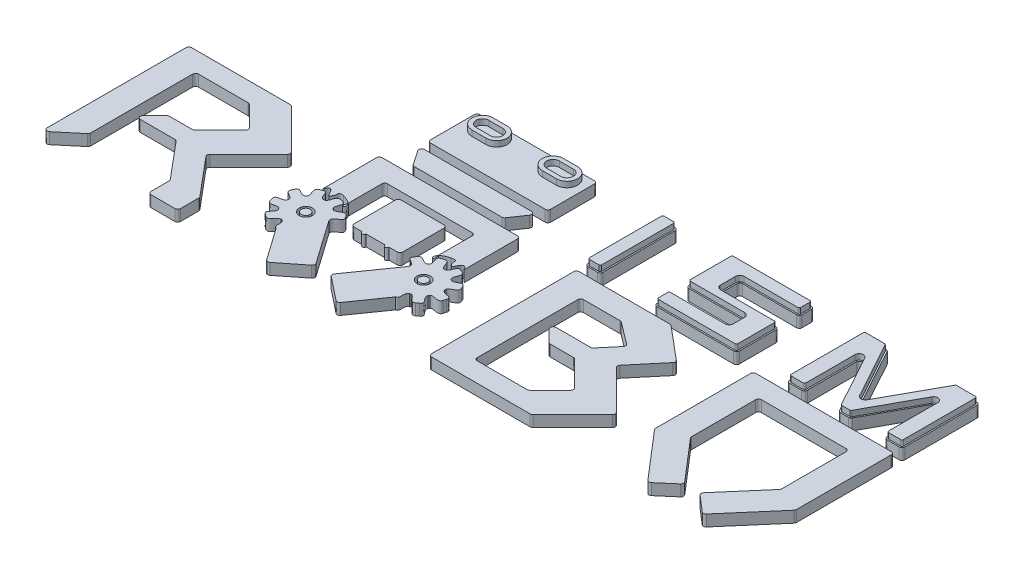
from build123d import *

# Parameters (mm, degrees)
BOSS_EXTRUDE1_DEPTH    = 40
BOSS_EXTRUDE1_2_DEPTH  = 40
BOSS_EXTRUDE1_3_DEPTH  = 40
SKETCH1_R              = 23.479951484
BOSS_EXTRUDE1_4_DEPTH  = 40
BOSS_EXTRUDE1_5_DEPTH  = 40
BOSS_EXTRUDE1_6_DEPTH  = 40
BOSS_EXTRUDE1_7_DEPTH  = 40
BOSS_EXTRUDE1_8_DEPTH  = 40
BOSS_EXTRUDE1_9_DEPTH  = 40
BOSS_EXTRUDE1_10_DEPTH = 40
BOSS_EXTRUDE1_11_DEPTH = 40
BOSS_EXTRUDE1_12_DEPTH = 40
SKETCH1_R_2            = 15.700674002
BOSS_EXTRUDE1_13_DEPTH = 40
BOSS_EXTRUDE1_14_DEPTH = 40
BOSS_EXTRUDE3_DEPTH    = 60


with BuildPart() as part:
    # Sketch1 → Boss-Extrude1 (new body)
    with BuildSketch(Plane(origin=(0, 0, 0), x_dir=(1, 0, 0), z_dir=(0, 1, 0))):
        with BuildLine():
            ThreePointArc((-83.841154636, -502.562147273), (-78.067337254, -511.625225143), (-67.41327854, -510.222591704))
            Line((-67.41327854, -510.222591704), (5.672852656, -448.896045973))
            ThreePointArc((5.672852656, -448.896045973), (8.30805443, -445.46178416), (9.244976559, -441.235601542))
            Line((9.244976559, -441.235601542), (9.244976559, -79.067718573))
            ThreePointArc((9.244976559, -79.067718573), (12.173908747, -71.996650761), (19.244976559, -69.067718573))
            Line((19.244976559, -69.067718573), (195.884712535, -69.067718573))
            ThreePointArc((195.884712535, -69.067718573), (199.711546859, -69.828923248), (202.955780347, -71.996650761))
            Line((202.955780347, -71.996650761), (275.159008185, -144.199878599))
            ThreePointArc((275.159008185, -144.199878599), (278.087940373, -151.270946411), (275.159008185, -158.342014222))
            Line((275.159008185, -158.342014222), (186.164058819, -247.336963589))
            ThreePointArc((186.164058819, -247.336963589), (182.91982533, -249.504691102), (179.092991007, -250.265895777))
            Line((179.092991007, -250.265895777), (97.377262254, -250.265895777))
            ThreePointArc((97.377262254, -250.265895777), (93.55042793, -251.027100452), (90.306194442, -253.194827965))
            Line((90.306194442, -253.194827965), (48.956172038, -294.544850369))
            ThreePointArc((48.956172038, -294.544850369), (46.788444525, -305.442752505), (56.02723985, -311.615918181))
            Line((56.02723985, -311.615918181), (178.572050049, -311.615918181))
            ThreePointArc((178.572050049, -311.615918181), (182.798232666, -312.552840311), (186.23249448, -315.188042084))
            Line((186.23249448, -315.188042084), (293.572185403, -443.11050437))
            ThreePointArc((293.572185403, -443.11050437), (295.30866718, -446.118179033), (295.911740972, -449.538380466))
            Line((295.911740972, -449.538380466), (295.911740972, -514.007216478))
            ThreePointArc((295.911740972, -514.007216478), (298.84067316, -521.07828429), (305.911740972, -524.007216478))
            Line((305.911740972, -524.007216478), (390.968639604, -524.007216478))
            ThreePointArc((390.968639604, -524.007216478), (398.039707415, -521.07828429), (400.968639604, -514.007216478))
            Line((400.968639604, -514.007216478), (400.968639604, -449.538380466))
            ThreePointArc((400.968639604, -449.538380466), (400.365565811, -446.118179033), (398.629084035, -443.11050437))
            Line((398.629084035, -443.11050437), (285.982871093, -308.863975404))
            ThreePointArc((285.982871093, -308.863975404), (283.652833308, -301.999905433), (286.572247712, -295.365031495))
            Line((286.572247712, -295.365031495), (423.897571792, -158.039707415))
            ThreePointArc((423.897571792, -158.039707415), (426.82650398, -150.968639604), (423.897571792, -143.897571792))
            Line((423.897571792, -143.897571792), (282.928932188, -2.928932188))
            ThreePointArc((282.928932188, -2.928932188), (279.6846987, -0.761204675), (275.857864376, 0))
            Line((275.857864376, 0), (-73.841154636, 0))
            ThreePointArc((-73.841154636, 0), (-80.912222448, -2.928932188), (-83.841154636, -10))
            Line((-83.841154636, -10), (-83.841154636, -502.562147273))
        make_face()
    extrude(amount=BOSS_EXTRUDE1_DEPTH)


with BuildPart() as body_2:
    # Sketch1 → Boss-Extrude1 2 (new body)
    with BuildSketch(Plane(origin=(0, 0, 0), x_dir=(1, 0, 0), z_dir=(0, 1, 0))):
        with BuildLine():
            ThreePointArc((652.48855838, 100.131688406), (643.639472479, 94.789335744), (644.245374102, 84.470424151))
            Line((644.245374102, 84.470424151), (678.948658716, 33.940090771))
            ThreePointArc((678.948658716, 33.940090771), (682.534195656, 30.752269125), (687.191842994, 29.601355025))
            Line((687.191842994, 29.601355025), (997.617211156, 29.601355025))
            ThreePointArc((997.617211156, 29.601355025), (1002.274858494, 30.752269125), (1005.860395434, 33.940090771))
            Line((1005.860395434, 33.940090771), (1040.563680048, 84.470424151))
            ThreePointArc((1040.563680048, 84.470424151), (1041.169581671, 94.789335744), (1032.32049577, 100.131688406))
            Line((1032.32049577, 100.131688406), (652.48855838, 100.131688406))
        make_face()
    extrude(amount=BOSS_EXTRUDE1_2_DEPTH)


with BuildPart() as body_3:
    # Sketch1 → Boss-Extrude1 3 (new body)
    with BuildSketch(Plane(origin=(0, 0, 0), x_dir=(1, 0, 0), z_dir=(0, 1, 0))):
        with BuildLine():
            ThreePointArc((682.229399989, -80.93218663), (685.158332177, -73.861118818), (692.229399989, -70.93218663))
            Line((692.229399989, -70.93218663), (992.552480119, -70.93218663))
            ThreePointArc((992.552480119, -70.93218663), (999.633135852, -73.870719757), (1002.552443298, -80.959323751))
            Line((1002.552443298, -80.959323751), (1002.229399989, -200))
            add(Edge.make_bspline(
                [(1002.321143043, -199.936731223), (1002.916384647, -199.672681374), (1002.869221848, -206.618046373), (1005.300085939, -210.274432477), (1005.476733332, -215.952627703), (1001.990741796, -221.163267153), (995.909387929, -215.485813233), (998.028575655, -207.97313609), (1000.304866893, -203.736781043), (1002.000226532, -200.210083042), (1002.229399989, -200)],
                knots=[0, 0, 0, 0, 0.110724906, 0.248079989, 0.387954105, 0.472257206, 0.599066129, 0.783281331, 0.956008664, 0.994591562, 0.994591562, 0.994591562, 0.994591562], degree=3))
            add(Edge.make_bspline(
                [(1032.936175395, -185.803412229), (1021.570991454, -188.809211315), (1011.635940703, -193.520317646), (1002.321143043, -199.936731223)],
                knots=[0, 0, 0, 0, 0.996726796, 0.996726796, 0.996726796, 0.996726796], degree=3))
            add(Edge.make_bspline(
                [(1092.229399989, -200), (1082.955729933, -178.396089637), (1071.367818565, -189.890922074), (1060.373427838, -216.512071312), (1045.340131066, -193.033805232), (1054.098134338, -180.895145494), (1032.936175395, -185.803412229)],
                knots=[0, 0, 0, 0, 0.39290012, 0.539016686, 0.696025891, 1, 1, 1, 1], degree=3))
            Line((1092.229399989, -200), (1092.229399989, -10))
            ThreePointArc((1092.229399989, -10), (1089.300467801, -2.928932188), (1082.229399989, 0))
            Line((1082.229399989, 0), (602.579654161, 0))
            ThreePointArc((602.579654161, 0), (595.508586349, -2.928932188), (592.579654161, -10))
            Line((592.579654161, -10), (592.579654161, -200))
            add(Edge.make_bspline(
                [(592.579654161, -200), (601.853324217, -178.396089637), (613.441235585, -189.890922074), (624.435626313, -216.512071312), (639.468923085, -193.033805232), (630.710919812, -180.895145494), (651.872878755, -185.803412229)],
                knots=[0, 0, 0, 0, 0.39290012, 0.539016686, 0.696025891, 1, 1, 1, 1], degree=3))
            add(Edge.make_bspline(
                [(651.872878755, -185.803412229), (662.734599882, -188.809211315), (672.822859275, -193.520317646), (682.137656935, -199.936731223)],
                knots=[0, 0, 0, 0, 0.996726796, 0.996726796, 0.996726796, 0.996726796], degree=3))
            add(Edge.make_bspline(
                [(682.137656935, -199.936731223), (681.542415331, -199.672681374), (681.58957813, -206.618046373), (679.158714039, -210.274432477), (678.982066646, -215.952627703), (682.468058183, -221.163267153), (688.549412049, -215.485813233), (686.430224323, -207.97313609), (684.153933085, -203.736781043), (682.458573446, -200.210083042), (682.229399989, -200)],
                knots=[0, 0, 0, 0, 0.110724906, 0.248079989, 0.387954105, 0.472257206, 0.599066129, 0.783281331, 0.956008664, 0.994591562, 0.994591562, 0.994591562, 0.994591562], degree=3))
            Line((682.229399989, -200), (682.229399989, -80.93218663))
        make_face()
    extrude(amount=BOSS_EXTRUDE1_3_DEPTH)


with BuildPart() as body_4:
    # Sketch1 → Boss-Extrude1 4 (new body)
    with BuildSketch(Plane(origin=(0, 0, 0), x_dir=(1, 0, 0), z_dir=(0, 1, 0))):
        with BuildLine():
            Line((631.515884705, -232.511357783), (627.180760519, -232.770775208))
            add(Edge.make_bspline(
                [(597.044693032, -206.242981492), (611.720771852, -199.704659562), (610.535191955, -220.555848352), (623.012373186, -233.297051044), (627.180760519, -232.770775208)],
                knots=[0, 0, 0, 0, 0.720995608, 1, 1, 1, 1], degree=3))
            add(Edge.make_bspline(
                [(587.411363618, -210.678143605), (592.070903264, -208.11875194), (597.044693032, -206.242981492)],
                knots=[0, 0, 0, 1, 1, 1], degree=2))
            add(Edge.make_bspline(
                [(587.411363618, -210.678143605), (572.247162281, -219.933048316), (593.18190623, -236.953733353), (587.411159366, -250.000847986)],
                knots=[0, 0, 0, 0, 1, 1, 1, 1], degree=3))
            Line((587.411159366, -250.000847986), (584.25701188, -252.986137377))
            add(Edge.make_bspline(
                [(544.119707731, -252.035759198), (551.159484033, -237.593512392), (563.654162943, -254.328525765), (581.402125514, -256.068675786), (584.25701188, -252.986137377)],
                knots=[0, 0, 0, 0, 0.720995608, 1, 1, 1, 1], degree=3))
            add(Edge.make_bspline(
                [(539.591016518, -261.625475276), (541.51528572, -256.669773162), (544.119707731, -252.035759198)],
                knots=[0, 0, 0, 1, 1, 1], degree=2))
            add(Edge.make_bspline(
                [(539.591016518, -261.625475276), (533.923502426, -278.462504332), (560.901132147, -278.0445115), (564.867007207, -291.748545746)],
                knots=[0, 0, 0, 0, 1, 1, 1, 1], degree=3))
            Line((564.867007207, -291.748545746), (564.336155949, -296.478912189))
            add(Edge.make_bspline(
                [(533.011846961, -321.134586888), (527.172676052, -300.009536697), (559.307721574, -313.070546725), (564.336155949, -296.478912189)],
                knots=[0, 0, 0, 0, 0.990676737, 0.990676737, 0.990676737, 0.990676737], degree=3))
            add(Edge.make_bspline(
                [(535.706818898, -331.391722201), (533.995430712, -326.358537734), (533.011846961, -321.134586888)],
                knots=[0, 0, 0, 1, 1, 1], degree=2))
            add(Edge.make_bspline(
                [(535.706818898, -331.391722201), (542.187884883, -347.932642584), (562.585267606, -330.271555374), (574.432087574, -338.220239307)],
                knots=[0, 0, 0, 0, 1, 1, 1, 1], degree=3))
            Line((574.432087574, -338.220239307), (577.066052857, -342.185134846))
            add(Edge.make_bspline(
                [(568.918602227, -381.20735514), (550.866617283, -368.777974541), (583.87894575, -358.127279597), (577.066052857, -342.185134846)],
                knots=[0, 0, 0, 0, 0.990676737, 0.990676737, 0.990676737, 0.990676737], degree=3))
            add(Edge.make_bspline(
                [(577.576229994, -387.332482079), (573.029961971, -384.576898209), (568.918602227, -381.20735514)],
                knots=[0, 0, 0, 1, 1, 1], degree=2))
            add(Edge.make_bspline(
                [(577.576229994, -387.332482079), (593.173313252, -395.837613309), (597.446286909, -369.197250709), (611.63079306, -367.671306776)],
                knots=[0, 0, 0, 0, 1, 1, 1, 1], degree=3))
            Line((611.63079306, -367.671306776), (616.197113254, -369.015512723))
            add(Edge.make_bspline(
                [(635.038803681, -404.145348053), (613.220729082, -406.227482366), (631.663505114, -376.848660983), (616.197113254, -369.015512723)],
                knots=[0, 0, 0, 0, 0.990676737, 0.990676737, 0.990676737, 0.990676737], degree=3))
            Line((635.038803681, -404.145348053), (630.925420829, -404.562583319))
            Line((630.925420829, -404.562583319), (711.105231, -518.603335225))
            ThreePointArc((711.105231, -518.603335225), (717.851495628, -522.748431507), (725.496915596, -520.688950228))
            Line((725.496915596, -520.688950228), (807.761022864, -455.491609359))
            ThreePointArc((807.761022864, -455.491609359), (811.446421063, -449.0886702), (809.730265252, -441.902948315))
            Line((809.730265252, -441.902948315), (701.4265828, -287.861259332))
            Line((701.4265828, -287.861259332), (700.418320092, -283.637042787))
            add(Edge.make_bspline(
                [(721.310023814, -249.352306844), (730.297488284, -262.670055361), (709.557202115, -265.123258023), (699.176206705, -279.623369464), (700.418320092, -283.637042787)],
                knots=[0, 0, 0, 0, 0.720995608, 1, 1, 1, 1], degree=3))
            add(Edge.make_bspline(
                [(715.269431682, -240.635487168), (718.599061004, -244.779804238), (721.310023814, -249.352306844)],
                knots=[0, 0, 0, 1, 1, 1], degree=2))
            add(Edge.make_bspline(
                [(715.269431682, -240.635487168), (703.52189384, -227.308761461), (690.395071391, -250.881070549), (676.544092069, -247.463601976)],
                knots=[0, 0, 0, 0, 1, 1, 1, 1], degree=3))
            Line((676.544092069, -247.463601976), (673.056443969, -244.87576314))
            add(Edge.make_bspline(
                [(667.022614047, -205.18320339), (682.467894998, -209.608159832), (668.156802305, -224.81902107), (669.52499043, -242.599526089), (673.056443969, -244.87576314)],
                knots=[0, 0, 0, 0, 0.720995608, 1, 1, 1, 1], degree=3))
            add(Edge.make_bspline(
                [(656.792188327, -202.388549893), (662.006748031, -203.423036482), (667.022614047, -205.18320339)],
                knots=[0, 0, 0, 1, 1, 1], degree=2))
            add(Edge.make_bspline(
                [(656.792188327, -202.388549893), (639.226798081, -199.730857489), (644.323056902, -226.226052702), (631.515884705, -232.511357783)],
                knots=[0, 0, 0, 0, 1, 1, 1, 1], degree=3))
        make_face()
        with Locations((633.489511742, -301.844471365)):
            Circle(SKETCH1_R, mode=Mode.SUBTRACT)
    extrude(amount=BOSS_EXTRUDE1_4_DEPTH)


with BuildPart() as body_5:
    # Sketch1 → Boss-Extrude1 5 (new body)
    with BuildSketch(Plane(origin=(0, 0, 0), x_dir=(1, 0, 0), z_dir=(0, 1, 0))):
        with BuildLine():
            ThreePointArc((928.749327437, -106.674051826), (925.820395249, -99.602984014), (918.749327437, -96.674051826))
            Line((918.749327437, -96.674051826), (766.059726713, -96.674051826))
            ThreePointArc((766.059726713, -96.674051826), (758.988658902, -99.602984014), (756.059726713, -106.674051826))
            Line((756.059726713, -106.674051826), (756.059726713, -252.93906301))
            ThreePointArc((756.059726713, -252.93906301), (758.988658902, -260.010130822), (766.059726713, -262.93906301))
            Line((766.059726713, -262.93906301), (794.54980176, -262.93906301))
            ThreePointArc((794.54980176, -262.93906301), (801.54980176, -269.93906301), (808.54980176, -262.93906301))
            Line((808.54980176, -262.93906301), (876.25925239, -262.93906301))
            ThreePointArc((876.25925239, -262.93906301), (883.25925239, -269.93906301), (890.25925239, -262.93906301))
            Line((890.25925239, -262.93906301), (918.749327437, -262.93906301))
            ThreePointArc((918.749327437, -262.93906301), (925.820395249, -260.010130822), (928.749327437, -252.93906301))
            Line((928.749327437, -252.93906301), (928.749327437, -106.674051826))
        make_face()
    extrude(amount=BOSS_EXTRUDE1_5_DEPTH)


with BuildPart() as body_6:
    # Sketch1 → Boss-Extrude1 6 (new body)
    with BuildSketch(Plane(origin=(0, 0, 0), x_dir=(1, 0, 0), z_dir=(0, 1, 0))):
        with BuildLine():
            ThreePointArc((2008.987736016, -80.932184675), (2011.916668205, -73.861116863), (2018.987736016, -70.932184675))
            Line((2018.987736016, -70.932184675), (2319.337990189, -70.932184675))
            ThreePointArc((2319.337990189, -70.932184675), (2326.409058001, -73.861116863), (2329.337990189, -80.932184675))
            Line((2329.337990189, -80.932184675), (2329.337990189, -308.380763367))
            ThreePointArc((2329.337990189, -308.380763367), (2328.71473723, -311.8559058), (2326.922667204, -314.897869672))
            Line((2326.922667204, -314.897869672), (2202.875014674, -459.2658353))
            ThreePointArc((2202.875014674, -459.2658353), (2200.488225077, -466.537828093), (2203.942585385, -473.367618619))
            Line((2203.942585385, -473.367618619), (2259.086837497, -520.750117883))
            ThreePointArc((2259.086837497, -520.750117883), (2266.35883029, -523.136907479), (2273.188620816, -519.682547172))
            Line((2273.188620816, -519.682547172), (2416.572413031, -352.81097835))
            ThreePointArc((2416.572413031, -352.81097835), (2418.364483058, -349.769014479), (2418.987736016, -346.293872046))
            Line((2418.987736016, -346.293872046), (2418.987736016, -10))
            ThreePointArc((2418.987736016, -10), (2416.058803828, -2.928932188), (2408.987736016, 0))
            Line((2408.987736016, 0), (1929.337990189, 0))
            ThreePointArc((1929.337990189, 0), (1922.266922377, -2.928932188), (1919.337990189, -10))
            Line((1919.337990189, -10), (1919.337990189, -346.293872046))
            ThreePointArc((1919.337990189, -346.293872046), (1919.961243147, -349.769014479), (1921.753313174, -352.81097835))
            Line((1921.753313174, -352.81097835), (2065.137105389, -519.682547172))
            ThreePointArc((2065.137105389, -519.682547172), (2071.966895915, -523.136907479), (2079.238888708, -520.750117883))
            Line((2079.238888708, -520.750117883), (2134.38314082, -473.367618619))
            ThreePointArc((2134.38314082, -473.367618619), (2137.837501128, -466.537828093), (2135.450711531, -459.2658353))
            Line((2135.450711531, -459.2658353), (2011.403059001, -314.897869672))
            ThreePointArc((2011.403059001, -314.897869672), (2009.610988975, -311.8559058), (2008.987736016, -308.380763367))
            Line((2008.987736016, -308.380763367), (2008.987736016, -80.932184675))
        make_face()
    extrude(amount=BOSS_EXTRUDE1_6_DEPTH)


with BuildPart() as body_7:
    # Sketch1 → Boss-Extrude1 7 (new body)
    with BuildSketch(Plane(origin=(0, 0, 0), x_dir=(1, 0, 0), z_dir=(0, 1, 0))):
        with BuildLine():
            Line((1120.472898201, -296.478912189), (1119.942046943, -291.748545746))
            add(Edge.make_bspline(
                [(1145.218037633, -261.625475276), (1150.885551724, -278.462504332), (1123.907922003, -278.0445115), (1119.942046943, -291.748545746)],
                knots=[0, 0, 0, 0, 1, 1, 1, 1], degree=3))
            add(Edge.make_bspline(
                [(1145.218037633, -261.625475276), (1143.29376843, -256.669773162), (1140.689346419, -252.035759198)],
                knots=[0, 0, 0, 1, 1, 1], degree=2))
            add(Edge.make_bspline(
                [(1140.689346419, -252.035759198), (1133.649570117, -237.593512392), (1121.154891207, -254.328525765), (1103.406928637, -256.068675786), (1100.55204227, -252.986137377)],
                knots=[0, 0, 0, 0, 0.720995608, 1, 1, 1, 1], degree=3))
            Line((1100.55204227, -252.986137377), (1097.397894784, -250.000847986))
            add(Edge.make_bspline(
                [(1097.397690532, -210.678143605), (1112.561891869, -219.933048316), (1091.62714792, -236.953733353), (1097.397894784, -250.000847986)],
                knots=[0, 0, 0, 0, 1, 1, 1, 1], degree=3))
            add(Edge.make_bspline(
                [(1097.397690532, -210.678143605), (1092.738150887, -208.11875194), (1087.764361118, -206.242981492)],
                knots=[0, 0, 0, 1, 1, 1], degree=2))
            add(Edge.make_bspline(
                [(1087.764361118, -206.242981492), (1073.088282298, -199.704659562), (1074.273862195, -220.555848352), (1061.796680964, -233.297051044), (1057.628293631, -232.770775208)],
                knots=[0, 0, 0, 0, 0.720995608, 1, 1, 1, 1], degree=3))
            Line((1057.628293631, -232.770775208), (1053.293169445, -232.511357783))
            add(Edge.make_bspline(
                [(1028.016865823, -202.388549893), (1045.582256069, -199.730857489), (1040.485997249, -226.226052702), (1053.293169445, -232.511357783)],
                knots=[0, 0, 0, 0, 1, 1, 1, 1], degree=3))
            add(Edge.make_bspline(
                [(1028.016865823, -202.388549893), (1022.80230612, -203.423036482), (1017.786440104, -205.18320339)],
                knots=[0, 0, 0, 1, 1, 1], degree=2))
            add(Edge.make_bspline(
                [(1017.786440104, -205.18320339), (1002.341159153, -209.608159832), (1016.652251846, -224.81902107), (1015.28406372, -242.599526089), (1011.752610181, -244.87576314)],
                knots=[0, 0, 0, 0, 0.720995608, 1, 1, 1, 1], degree=3))
            Line((1011.752610181, -244.87576314), (1008.264962081, -247.463601976))
            add(Edge.make_bspline(
                [(969.539622469, -240.635487168), (981.28716031, -227.308761461), (994.413982759, -250.881070549), (1008.264962081, -247.463601976)],
                knots=[0, 0, 0, 0, 1, 1, 1, 1], degree=3))
            add(Edge.make_bspline(
                [(969.539622469, -240.635487168), (966.209993146, -244.779804238), (963.499030337, -249.352306844)],
                knots=[0, 0, 0, 1, 1, 1], degree=2))
            add(Edge.make_bspline(
                [(963.499030337, -249.352306844), (954.511565866, -262.670055361), (975.251852035, -265.123258023), (985.632847445, -279.623369464), (984.390734058, -283.637042787)],
                knots=[0, 0, 0, 0, 0.720995608, 1, 1, 1, 1], degree=3))
            Line((984.390734058, -283.637042787), (983.382471351, -287.861259332))
            Line((983.382471351, -287.861259332), (875.078788898, -441.902948315))
            ThreePointArc((875.078788898, -441.902948315), (873.362633088, -449.0886702), (877.048031286, -455.491609359))
            Line((877.048031286, -455.491609359), (959.312138554, -520.688950228))
            ThreePointArc((959.312138554, -520.688950228), (966.957558522, -522.748431507), (973.70382315, -518.603335225))
            Line((973.70382315, -518.603335225), (1053.883633321, -404.562583319))
            Line((1053.883633321, -404.562583319), (1049.77025047, -404.145348053))
            add(Edge.make_bspline(
                [(1049.77025047, -404.145348053), (1071.588325068, -406.227482366), (1053.145549036, -376.848660983), (1068.611940897, -369.015512723)],
                knots=[0, 0, 0, 0, 0.990676737, 0.990676737, 0.990676737, 0.990676737], degree=3))
            Line((1068.611940897, -369.015512723), (1073.178261091, -367.671306776))
            add(Edge.make_bspline(
                [(1107.232824157, -387.332482079), (1091.635740898, -395.837613309), (1087.362767241, -369.197250709), (1073.178261091, -367.671306776)],
                knots=[0, 0, 0, 0, 1, 1, 1, 1], degree=3))
            add(Edge.make_bspline(
                [(1107.232824157, -387.332482079), (1111.779092179, -384.576898209), (1115.890451923, -381.20735514)],
                knots=[0, 0, 0, 1, 1, 1], degree=2))
            add(Edge.make_bspline(
                [(1115.890451923, -381.20735514), (1133.942436867, -368.777974541), (1100.9301084, -358.127279597), (1107.743001294, -342.185134846)],
                knots=[0, 0, 0, 0, 0.990676737, 0.990676737, 0.990676737, 0.990676737], degree=3))
            Line((1107.743001294, -342.185134846), (1110.376966576, -338.220239307))
            add(Edge.make_bspline(
                [(1149.102235252, -331.391722201), (1142.621169267, -347.932642584), (1122.223786544, -330.271555374), (1110.376966576, -338.220239307)],
                knots=[0, 0, 0, 0, 1, 1, 1, 1], degree=3))
            add(Edge.make_bspline(
                [(1149.102235252, -331.391722201), (1150.813623439, -326.358537734), (1151.797207189, -321.134586888)],
                knots=[0, 0, 0, 1, 1, 1], degree=2))
            add(Edge.make_bspline(
                [(1151.797207189, -321.134586888), (1157.636378098, -300.009536697), (1125.501332576, -313.070546725), (1120.472898201, -296.478912189)],
                knots=[0, 0, 0, 0, 0.990676737, 0.990676737, 0.990676737, 0.990676737], degree=3))
        make_face()
        with Locations((1051.319542408, -301.844471365)):
            Circle(SKETCH1_R, mode=Mode.SUBTRACT)
    extrude(amount=BOSS_EXTRUDE1_7_DEPTH)


with BuildPart() as body_8:
    # Sketch1 → Boss-Extrude1 8 (new body)
    with BuildSketch(Plane(origin=(0, 0, 0), x_dir=(1, 0, 0), z_dir=(0, 1, 0))):
        with BuildLine():
            Line((1662.457036184, -215.999302485), (1747.763937594, -114.334496257))
            ThreePointArc((1747.763937594, -114.334496257), (1750.065440144, -107.035062732), (1746.53136926, -100.246175729))
            Line((1746.53136926, -100.246175729), (1630.871017208, -3.19561698))
            ThreePointArc((1630.871017208, -3.19561698), (1627.863342544, -1.459135203), (1624.443141111, -0.856061411))
            Line((1624.443141111, -0.856061411), (1302.633010455, -0.856061411))
            ThreePointArc((1302.633010455, -0.856061411), (1295.561942643, -3.784993599), (1292.633010455, -10.856061411))
            Line((1292.633010455, -10.856061411), (1292.633010455, -514.863277889))
            ThreePointArc((1292.633010455, -514.863277889), (1295.561942643, -521.934345701), (1302.633010455, -524.863277889))
            Line((1302.633010455, -524.863277889), (1652.332029468, -524.863277889))
            ThreePointArc((1652.332029468, -524.863277889), (1656.158863791, -524.102073214), (1659.40309728, -521.934345701))
            Line((1659.40309728, -521.934345701), (1800.371736883, -380.965706097))
            ThreePointArc((1800.371736883, -380.965706097), (1803.300669071, -373.894638285), (1800.371736883, -366.823570473))
            Line((1800.371736883, -366.823570473), (1663.046412804, -229.498246394))
            ThreePointArc((1663.046412804, -229.498246394), (1660.1269984, -222.863372456), (1662.457036184, -215.999302485))
        make_face()
        with BuildLine():
            ThreePointArc((1385.719141651, -88.964599765), (1388.648073839, -81.893531953), (1395.719141651, -78.964599765))
            Line((1395.719141651, -78.964599765), (1525.722270668, -78.964599765))
            ThreePointArc((1525.722270668, -78.964599765), (1528.88191809, -79.476890444), (1531.717833928, -80.961274132))
            Line((1531.717833928, -80.961274132), (1608.605170165, -138.560191064))
            ThreePointArc((1608.605170165, -138.560191064), (1612.543716445, -145.417450539), (1610.270051336, -152.991392794))
            Line((1610.270051336, -152.991392794), (1562.706659572, -209.675235805))
            ThreePointArc((1562.706659572, -209.675235805), (1559.272397758, -212.310437578), (1555.04621514, -213.247359708))
            Line((1555.04621514, -213.247359708), (1432.501404941, -213.247359708))
            ThreePointArc((1432.501404941, -213.247359708), (1423.262609616, -219.420525384), (1425.430337129, -230.31842752))
            Line((1425.430337129, -230.31842752), (1466.780359534, -271.668449924))
            ThreePointArc((1466.780359534, -271.668449924), (1470.024593022, -273.836177437), (1473.851427346, -274.597382112))
            Line((1473.851427346, -274.597382112), (1555.567156098, -274.597382112))
            ThreePointArc((1555.567156098, -274.597382112), (1559.393990422, -275.358586787), (1562.63822391, -277.5263143))
            Line((1562.63822391, -277.5263143), (1651.633173276, -366.521263666))
            ThreePointArc((1651.633173276, -366.521263666), (1654.562105464, -373.592331478), (1651.633173276, -380.66339929))
            Line((1651.633173276, -380.66339929), (1579.429945439, -452.866627127))
            ThreePointArc((1579.429945439, -452.866627127), (1576.185711951, -455.034354641), (1572.358877627, -455.795559316))
            Line((1572.358877627, -455.795559316), (1395.719141651, -455.795559316))
            ThreePointArc((1395.719141651, -455.795559316), (1388.648073839, -452.866627127), (1385.719141651, -445.795559316))
            Line((1385.719141651, -445.795559316), (1385.719141651, -88.964599765))
        make_face(mode=Mode.SUBTRACT)
    extrude(amount=BOSS_EXTRUDE1_8_DEPTH)


with BuildPart() as body_9:
    # Sketch1 → Boss-Extrude1 9 (new body)
    with BuildSketch(Plane(origin=(0, 0, 0), x_dir=(1, 0, 0), z_dir=(0, 1, 0))):
        with BuildLine():
            ThreePointArc((1538.388405239, 39.601355025), (1541.317337428, 32.530287214), (1548.388405239, 29.601355025))
            Line((1548.388405239, 29.601355025), (1820.35387848, 29.601355025))
            ThreePointArc((1820.35387848, 29.601355025), (1827.424946292, 32.530287214), (1830.35387848, 39.601355025))
            Line((1830.35387848, 39.601355025), (1830.35387848, 169.219093269))
            ThreePointArc((1830.35387848, 169.219093269), (1827.424946292, 176.290161081), (1820.35387848, 179.219093269))
            Line((1820.35387848, 179.219093269), (1629.161436814, 179.219093269))
            ThreePointArc((1629.161436814, 179.219093269), (1622.090369002, 182.148025457), (1619.161436814, 189.219093269))
            Line((1619.161436814, 189.219093269), (1619.161436814, 242.406013522))
            ThreePointArc((1619.161436814, 242.406013522), (1622.090369002, 249.477081334), (1629.161436814, 252.406013522))
            Line((1629.161436814, 252.406013522), (1820.35387848, 252.406013522))
            ThreePointArc((1820.35387848, 252.406013522), (1827.424946292, 255.33494571), (1830.35387848, 262.406013522))
            Line((1830.35387848, 262.406013522), (1830.35387848, 295.071566962))
            ThreePointArc((1830.35387848, 295.071566962), (1827.424946292, 302.142634774), (1820.35387848, 305.071566962))
            Line((1820.35387848, 305.071566962), (1549.098731745, 305.071566962))
            ThreePointArc((1549.098731745, 305.071566962), (1542.027663933, 302.142634774), (1539.098731745, 295.071566962))
            Line((1539.098731745, 295.071566962), (1539.098731745, 152.177130532))
            ThreePointArc((1539.098731745, 152.177130532), (1542.027663933, 145.10606272), (1549.098731745, 142.177130532))
            Line((1549.098731745, 142.177130532), (1741.1936436, 142.177130532))
            ThreePointArc((1741.1936436, 142.177130532), (1748.264711412, 139.248198343), (1751.1936436, 132.177130532))
            Line((1751.1936436, 132.177130532), (1751.1936436, 92.479963873))
            ThreePointArc((1751.1936436, 92.479963873), (1748.264711412, 85.408896061), (1741.1936436, 82.479963873))
            Line((1741.1936436, 82.479963873), (1548.388405239, 82.479963873))
            ThreePointArc((1548.388405239, 82.479963873), (1541.317337428, 79.551031685), (1538.388405239, 72.479963873))
            Line((1538.388405239, 72.479963873), (1538.388405239, 39.601355025))
        make_face()
    extrude(amount=BOSS_EXTRUDE1_9_DEPTH)


with BuildPart() as body_10:
    # Sketch1 → Boss-Extrude1 10 (new body)
    with BuildSketch(Plane(origin=(0, 0, 0), x_dir=(1, 0, 0), z_dir=(0, 1, 0))):
        with BuildLine():
            ThreePointArc((633.489511742, 140.757765273), (636.41844393, 133.686697461), (643.489511742, 130.757765273))
            Line((643.489511742, 130.757765273), (1049.913948272, 130.757765273))
            ThreePointArc((1049.913948272, 130.757765273), (1056.985016084, 133.686697461), (1059.913948272, 140.757765273))
            Line((1059.913948272, 140.757765273), (1059.913948272, 295.534833979))
            ThreePointArc((1059.913948272, 295.534833979), (1056.985016084, 302.605901791), (1049.913948272, 305.534833979))
            Line((1049.913948272, 305.534833979), (643.489511742, 305.534833979))
            ThreePointArc((643.489511742, 305.534833979), (636.41844393, 302.605901791), (633.489511742, 295.534833979))
            Line((633.489511742, 295.534833979), (633.489511742, 140.757765273))
        make_face()
    extrude(amount=BOSS_EXTRUDE1_10_DEPTH)

    # Sketch3 → Boss-Extrude3 (add)
    with BuildSketch(Plane(origin=(0, 0, 0), x_dir=(1, 0, 0), z_dir=(0, 1, 0))):
        with BuildLine():
            Line((946.701730007, 299.202225887), (996.701730007, 299.202225887))
            ThreePointArc((996.701730007, 299.202225887), (1034.063389091, 261.840566803), (996.701730007, 224.478907719))
            Line((996.701730007, 224.478907719), (946.701730007, 224.478907719))
            ThreePointArc((946.701730007, 224.478907719), (909.340070923, 261.840566803), (946.701730007, 299.202225887))
        make_face()
        with BuildLine():
            Line((946.701730007, 284.202225887), (996.701730007, 284.202225887))
            ThreePointArc((996.701730007, 284.202225887), (1019.063389091, 261.840566803), (996.701730007, 239.478907719))
            Line((996.701730007, 239.478907719), (946.701730007, 239.478907719))
            ThreePointArc((946.701730007, 239.478907719), (924.340070923, 261.840566803), (946.701730007, 284.202225887))
        make_face(mode=Mode.SUBTRACT)
        with BuildLine():
            Line((746.701730007, 299.202225887), (696.701730007, 299.202225887))
            ThreePointArc((696.701730007, 299.202225887), (659.340070923, 261.840566803), (696.701730007, 224.478907719))
            Line((696.701730007, 224.478907719), (746.701730007, 224.478907719))
            ThreePointArc((746.701730007, 224.478907719), (784.063389091, 261.840566803), (746.701730007, 299.202225887))
        make_face()
        with BuildLine():
            Line((746.701730007, 239.478907719), (696.701730007, 239.478907719))
            ThreePointArc((696.701730007, 239.478907719), (674.340070923, 261.840566803), (696.701730007, 284.202225887))
            Line((696.701730007, 284.202225887), (746.701730007, 284.202225887))
            ThreePointArc((746.701730007, 284.202225887), (769.063389091, 261.840566803), (746.701730007, 239.478907719))
        make_face(mode=Mode.SUBTRACT)
        with BuildLine():
            Line((1302.633010455, 35.064622043), (1336.336264837, 35.064622043))
            ThreePointArc((1336.336264837, 35.064622043), (1339.871798743, 36.529088137), (1341.336264837, 40.064622043))
            Line((1341.336264837, 40.064622043), (1341.336264837, 295.534833979))
            ThreePointArc((1341.336264837, 295.534833979), (1339.871798743, 299.070367885), (1336.336264837, 300.534833979))
            Line((1336.336264837, 300.534833979), (1302.633010455, 300.534833979))
            ThreePointArc((1302.633010455, 300.534833979), (1299.097476549, 299.070367885), (1297.633010455, 295.534833979))
            Line((1297.633010455, 295.534833979), (1297.633010455, 40.064622043))
            ThreePointArc((1297.633010455, 40.064622043), (1299.097476549, 36.529088137), (1302.633010455, 35.064622043))
        make_face()
        with BuildLine():
            Line((1825.35387848, 262.406013522), (1825.35387848, 295.071566962))
            ThreePointArc((1825.35387848, 295.071566962), (1823.889412386, 298.607100868), (1820.35387848, 300.071566962))
            Line((1820.35387848, 300.071566962), (1549.098731745, 300.071566962))
            ThreePointArc((1549.098731745, 300.071566962), (1545.563197839, 298.607100868), (1544.098731745, 295.071566962))
            Line((1544.098731745, 295.071566962), (1544.098731745, 152.177130532))
            ThreePointArc((1544.098731745, 152.177130532), (1545.563197839, 148.641596626), (1549.098731745, 147.177130532))
            Line((1549.098731745, 147.177130532), (1741.1936436, 147.177130532))
            ThreePointArc((1741.1936436, 147.177130532), (1751.800245318, 142.783732249), (1756.1936436, 132.177130532))
            Line((1756.1936436, 132.177130532), (1756.1936436, 92.479963873))
            ThreePointArc((1756.1936436, 92.479963873), (1751.800245318, 81.873362155), (1741.1936436, 77.479963873))
            Line((1741.1936436, 77.479963873), (1548.388405239, 77.479963873))
            ThreePointArc((1548.388405239, 77.479963873), (1544.852871334, 76.015497779), (1543.388405239, 72.479963873))
            Line((1543.388405239, 72.479963873), (1543.388405239, 39.601355025))
            ThreePointArc((1543.388405239, 39.601355025), (1544.852871334, 36.06582112), (1548.388405239, 34.601355025))
            Line((1548.388405239, 34.601355025), (1820.35387848, 34.601355025))
            ThreePointArc((1820.35387848, 34.601355025), (1823.889412386, 36.06582112), (1825.35387848, 39.601355025))
            Line((1825.35387848, 39.601355025), (1825.35387848, 169.219093269))
            ThreePointArc((1825.35387848, 169.219093269), (1823.889412386, 172.754627175), (1820.35387848, 174.219093269))
            Line((1820.35387848, 174.219093269), (1629.161436814, 174.219093269))
            ThreePointArc((1629.161436814, 174.219093269), (1618.554835096, 178.612491551), (1614.161436814, 189.219093269))
            Line((1614.161436814, 189.219093269), (1614.161436814, 242.406013522))
            ThreePointArc((1614.161436814, 242.406013522), (1618.554835096, 253.01261524), (1629.161436814, 257.406013522))
            Line((1629.161436814, 257.406013522), (1820.35387848, 257.406013522))
            ThreePointArc((1820.35387848, 257.406013522), (1823.889412386, 258.870479616), (1825.35387848, 262.406013522))
        make_face()
        with BuildLine():
            Line((2361.063986428, 213.297194412), (2361.063986428, 38.62435626))
            ThreePointArc((2361.063986428, 38.62435626), (2362.528452522, 35.088822354), (2366.063986428, 33.62435626))
            Line((2366.063986428, 33.62435626), (2408.730462105, 33.62435626))
            ThreePointArc((2408.730462105, 33.62435626), (2412.26599601, 35.088822354), (2413.730462105, 38.62435626))
            Line((2413.730462105, 38.62435626), (2413.730462105, 294.094568197))
            ThreePointArc((2413.730462105, 294.094568197), (2412.26599601, 297.630102102), (2408.730462105, 299.094568197))
            Line((2408.730462105, 299.094568197), (2341.969298208, 299.094568197))
            ThreePointArc((2341.969298208, 299.094568197), (2339.426857705, 298.39991328), (2337.590864719, 296.50896671))
            Line((2337.590864719, 296.50896671), (2227.013669475, 95.980805365))
            ThreePointArc((2227.013669475, 95.980805365), (2213.864434927, 88.224007379), (2200.729634248, 96.005221635))
            Line((2200.729634248, 96.005221635), (2090.119275769, 297.47782672))
            ThreePointArc((2090.119275769, 297.47782672), (2088.282802991, 299.374548416), (2085.736364182, 300.071566962))
            Line((2085.736364182, 300.071566962), (2018.987736016, 300.071566962))
            ThreePointArc((2018.987736016, 300.071566962), (2015.452202111, 298.607100868), (2013.987736016, 295.071566962))
            Line((2013.987736016, 295.071566962), (2013.987736016, 39.601355025))
            ThreePointArc((2013.987736016, 39.601355025), (2015.452202111, 36.06582112), (2018.987736016, 34.601355025))
            Line((2018.987736016, 34.601355025), (2061.654211693, 34.601355025))
            ThreePointArc((2061.654211693, 34.601355025), (2065.189745599, 36.06582112), (2066.654211693, 39.601355025))
            Line((2066.654211693, 39.601355025), (2066.654211693, 213.311845432))
            ThreePointArc((2066.654211693, 213.311845432), (2077.937003812, 227.843960404), (2094.811860436, 220.514364406))
            Line((2094.811860436, 220.514364406), (2195.407198984, 36.745583705))
            ThreePointArc((2195.407198984, 36.745583705), (2197.238857493, 34.848058826), (2199.781159832, 34.146437577))
            Line((2199.781159832, 34.146437577), (2227.927447219, 34.079325005))
            ThreePointArc((2227.927447219, 34.079325005), (2230.483724495, 34.775096976), (2232.325684005, 36.679260129))
            Line((2232.325684005, 36.679260129), (2332.905042269, 220.497346398))
            ThreePointArc((2332.905042269, 220.497346398), (2349.779887235, 227.829643662), (2361.063986428, 213.297194412))
        make_face()
    extrude(amount=BOSS_EXTRUDE3_DEPTH)


with BuildPart() as body_11:
    # Sketch1 → Boss-Extrude1 11 (new body)
    with BuildSketch(Plane(origin=(0, 0, 0), x_dir=(1, 0, 0), z_dir=(0, 1, 0))):
        with BuildLine():
            ThreePointArc((1292.633010455, 40.064622043), (1295.561942643, 32.993554231), (1302.633010455, 30.064622043))
            Line((1302.633010455, 30.064622043), (1336.336264837, 30.064622043))
            ThreePointArc((1336.336264837, 30.064622043), (1343.407332649, 32.993554231), (1346.336264837, 40.064622043))
            Line((1346.336264837, 40.064622043), (1346.336264837, 295.534833979))
            ThreePointArc((1346.336264837, 295.534833979), (1343.407332649, 302.605901791), (1336.336264837, 305.534833979))
            Line((1336.336264837, 305.534833979), (1302.633010455, 305.534833979))
            ThreePointArc((1302.633010455, 305.534833979), (1295.561942643, 302.605901791), (1292.633010455, 295.534833979))
            Line((1292.633010455, 295.534833979), (1292.633010455, 40.064622043))
        make_face()
    extrude(amount=BOSS_EXTRUDE1_11_DEPTH)


with BuildPart() as body_12:
    # Sketch1 → Boss-Extrude1 12 (new body)
    with BuildSketch(Plane(origin=(0, 0, 0), x_dir=(1, 0, 0), z_dir=(0, 1, 0))):
        with BuildLine():
            ThreePointArc((2356.063986428, 38.62435626), (2358.992918616, 31.553288448), (2366.063986428, 28.62435626))
            Line((2366.063986428, 28.62435626), (2408.730462105, 28.62435626))
            ThreePointArc((2408.730462105, 28.62435626), (2415.801529916, 31.553288448), (2418.730462105, 38.62435626))
            Line((2418.730462105, 38.62435626), (2418.730462105, 294.094568197))
            ThreePointArc((2418.730462105, 294.094568197), (2415.801529916, 301.165636008), (2408.730462105, 304.094568197))
            Line((2408.730462105, 304.094568197), (2341.969298208, 304.094568197))
            ThreePointArc((2341.969298208, 304.094568197), (2336.884417201, 302.705258363), (2333.212431231, 298.923365224))
            Line((2333.212431231, 298.923365224), (2222.635235987, 98.395203879))
            ThreePointArc((2222.635235987, 98.395203879), (2213.869079621, 93.224005222), (2205.112545835, 98.411481392))
            Line((2205.112545835, 98.411481392), (2094.502187356, 299.884086477))
            ThreePointArc((2094.502187356, 299.884086477), (2090.829241799, 303.67752987), (2085.736364182, 305.071566962))
            Line((2085.736364182, 305.071566962), (2018.987736016, 305.071566962))
            ThreePointArc((2018.987736016, 305.071566962), (2011.916668205, 302.142634774), (2008.987736016, 295.071566962))
            Line((2008.987736016, 295.071566962), (2008.987736016, 39.601355025))
            ThreePointArc((2008.987736016, 39.601355025), (2011.916668205, 32.530287214), (2018.987736016, 29.601355025))
            Line((2018.987736016, 29.601355025), (2061.654211693, 29.601355025))
            ThreePointArc((2061.654211693, 29.601355025), (2068.725279505, 32.530287214), (2071.654211693, 39.601355025))
            Line((2071.654211693, 39.601355025), (2071.654211693, 213.311845432))
            ThreePointArc((2071.654211693, 213.311845432), (2079.176073106, 222.99992208), (2090.425977521, 218.113524748))
            Line((2090.425977521, 218.113524748), (2191.02131607, 34.344744047))
            ThreePointArc((2191.02131607, 34.344744047), (2194.684633088, 30.54969429), (2199.769237766, 29.14645179))
            Line((2199.769237766, 29.14645179), (2227.915525152, 29.079339219))
            ThreePointArc((2227.915525152, 29.079339219), (2233.028079705, 30.470883161), (2236.711998724, 34.279209467))
            Line((2236.711998724, 34.279209467), (2337.291356989, 218.097295736))
            ThreePointArc((2337.291356989, 218.097295736), (2348.541253633, 222.985493912), (2356.063986428, 213.297194412))
            Line((2356.063986428, 213.297194412), (2356.063986428, 38.62435626))
        make_face()
    extrude(amount=BOSS_EXTRUDE1_12_DEPTH)


with BuildPart() as body_13:
    # Sketch1 → Boss-Extrude1 13 (new body)
    with BuildSketch(Plane(origin=(0, 0, 0), x_dir=(1, 0, 0), z_dir=(0, 1, 0))):
        with Locations((633.489511742, -301.844471365)):
            Circle(SKETCH1_R_2)
    extrude(amount=BOSS_EXTRUDE1_13_DEPTH)


with BuildPart() as body_14:
    # Sketch1 → Boss-Extrude1 14 (new body)
    with BuildSketch(Plane(origin=(0, 0, 0), x_dir=(1, 0, 0), z_dir=(0, 1, 0))):
        with Locations((1051.319542408, -301.844471365)):
            Circle(SKETCH1_R_2)
    extrude(amount=BOSS_EXTRUDE1_14_DEPTH)


solid = Compound([part.part, body_2.part, body_3.part, body_4.part, body_5.part, body_6.part, body_7.part, body_8.part, body_9.part, body_10.part, body_11.part, body_12.part, body_13.part, body_14.part])
